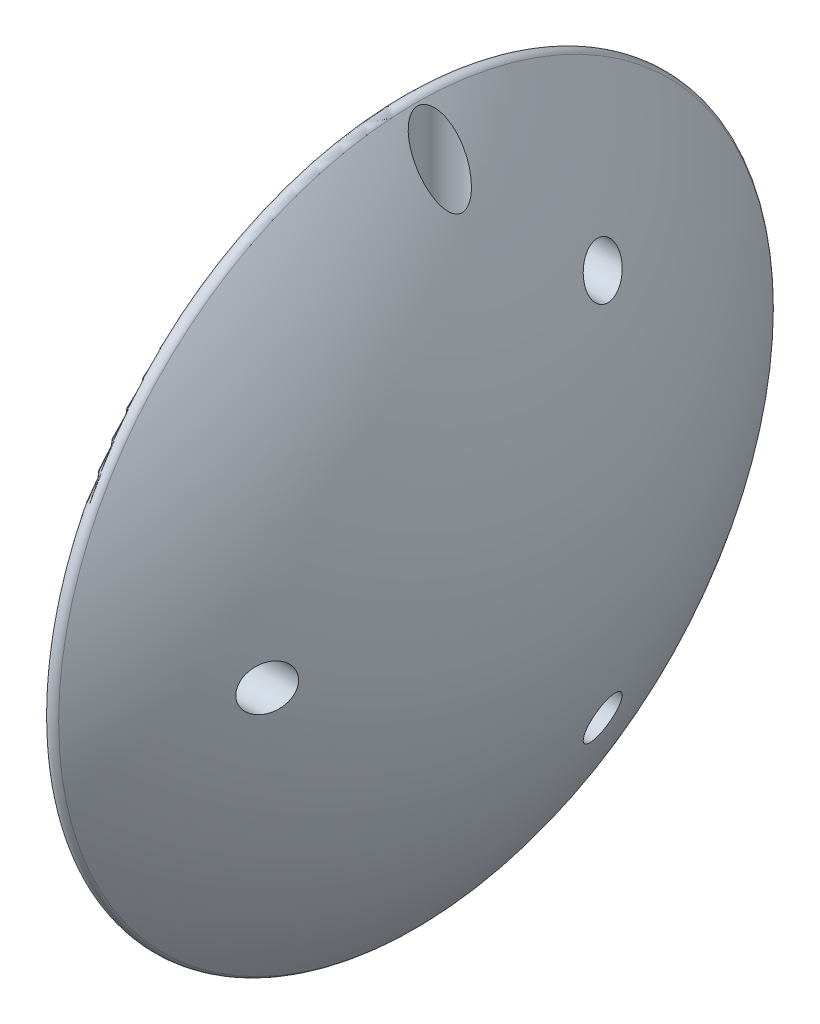
from build123d import *

# Parameters (mm, degrees)
CUT_EXTRUDE1_DEPTH      = 15
SKETCH3_R               = 1.4
CUT_EXTRUDE2_DEPTH      = 49.748756204
CUT_EXTRUDE3_START      = -20
SKETCH4_R               = 3
CUT_EXTRUDE3_DEPTH      = 29.748756266
FILLET1_R               = 1
CHAMFER1_SIZE           = 1
SKETCH5_R               = 1.4
SKETCH5_R_2             = 1.400000586
CUT_EXTRUDE4_DEPTH      = 1.0000001
CUT_EXTRUDE4_DEPTH_BACK = 18.75
CUT_EXTRUDE5_START      = -5
SKETCH6_R               = 3
CUT_EXTRUDE5_DEPTH      = 10


with BuildPart() as part:
    # Sketch1 → Revolve1 (revolve)
    with BuildSketch(Plane.XY):
        with BuildLine():
            Line((62.25, 50.248756204), (62.25, 0))
            Line((62.25, 0), (80, 0))
            ThreePointArc((80, 0), (75.432088663, 26.645825189), (62.25, 50.248756204))
        make_face()
    revolve(axis=Axis((62.25, 0, 0), (1, 0, 0)))

    # Sketch2 → Cut-Extrude1 (cut)
    with BuildSketch(Plane.ZY.offset(-62.25)):
        with BuildLine():
            Line((-1.322875656, 1.5), (1.322875656, 1.5))
            ThreePointArc((1.322875656, 1.5), (0, -2), (-1.322875656, 1.5))
        make_face()
    extrude(amount=-CUT_EXTRUDE1_DEPTH, mode=Mode.SUBTRACT)

    # Sketch3 → Cut-Extrude2 (cut, through all)
    with BuildSketch(Plane.XZ.offset(-1.5)):
        with Locations((67.25, 0)):
            Circle(SKETCH3_R)
    extrude(amount=-CUT_EXTRUDE2_DEPTH, mode=Mode.SUBTRACT)

    # Sketch4 → Cut-Extrude3 (cut, through all)
    with BuildSketch(Plane.XZ.offset(-1.5).offset(CUT_EXTRUDE3_START)):
        with Locations((67.25, 0)):
            Circle(SKETCH4_R)
    extrude(amount=-CUT_EXTRUDE3_DEPTH, mode=Mode.SUBTRACT)

    # Fillet1
    fillet1_edges = [part.edges().sort_by_distance(p)[0] for p in [
        (62.25, -50.248756204, 0),
    ]]
    fillet(fillet1_edges, radius=FILLET1_R)

    # Chamfer1
    chamfer1_edges = [part.edges().sort_by_distance(p)[0] for p in [
        (62.25, -2, 0),
        (62.25, 1.5, 0),
    ]]
    chamfer(chamfer1_edges, length=CHAMFER1_SIZE)

    # Sketch5 → Cut-Extrude4 (cut, two sides)
    with BuildSketch(Plane.ZY.offset(-62.25)) as cut_extrude4_sk:
        with Locations((-15, -25.980762114)):
            Circle(SKETCH5_R)
        with Locations((30, 0)):
            Circle(SKETCH5_R_2)
        with Locations((-15, 25.980762114)):
            Circle(SKETCH5_R)
    extrude(amount=CUT_EXTRUDE4_DEPTH, mode=Mode.SUBTRACT)
    extrude(cut_extrude4_sk.sketch, amount=-CUT_EXTRUDE4_DEPTH_BACK, mode=Mode.SUBTRACT)

    # Sketch6 → Cut-Extrude5 (cut)
    with BuildSketch(Plane.ZY.offset(-62.25).offset(CUT_EXTRUDE5_START)):
        with Locations((-15, 25.980762114)):
            Circle(SKETCH6_R)
        with Locations((30, 0)):
            Circle(SKETCH6_R)
        with Locations((-15, -25.980762114)):
            Circle(SKETCH6_R)
    extrude(amount=-CUT_EXTRUDE5_DEPTH, mode=Mode.SUBTRACT)


solid = part.part
